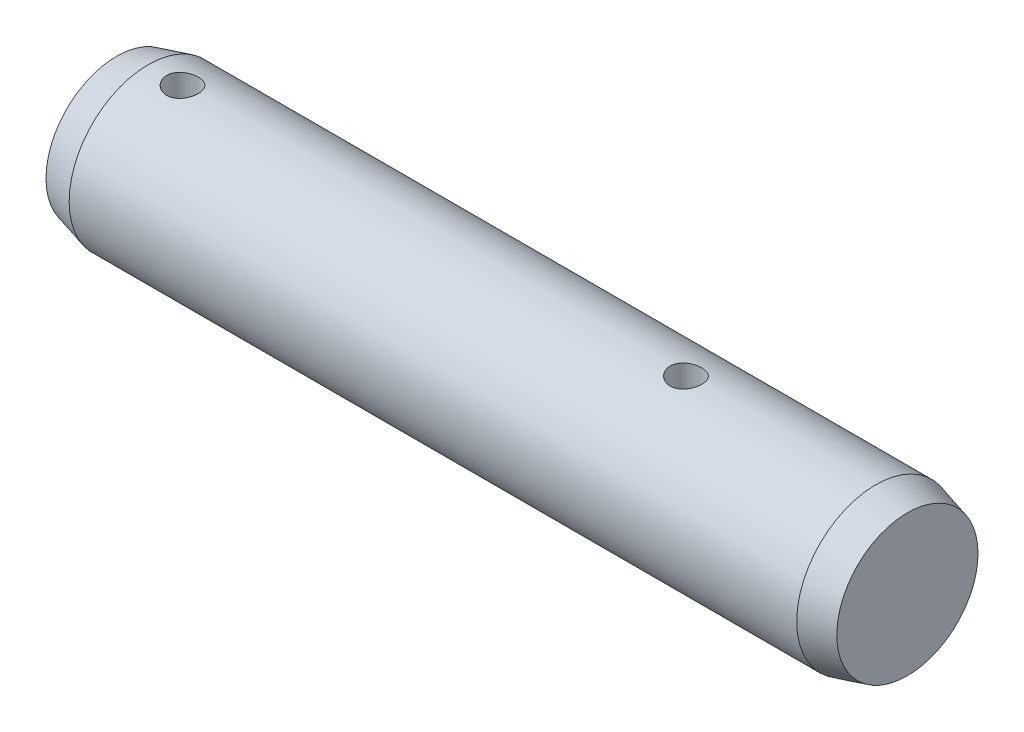
from build123d import *

# Parameters (mm, degrees)
SKETCH2_R           = 3
EXTRUDE1_DEPTH      = 13.8
EXTRUDE1_DEPTH_BACK = 13.8
SKETCH3_R           = 3
EXTRUDE2_DEPTH      = 1.2
EXTRUDE2_TAPER      = 15
SKETCH4_R           = 3
EXTRUDE3_DEPTH      = 1.2
EXTRUDE3_TAPER      = 15
SKETCH6_R           = 0.6
CUT_EXTRUDE1_DEPTH  = 5


with BuildPart() as part:
    # Sketch2 → Extrude1 (new body, two sides)
    with BuildSketch(Plane(origin=(0, 0, 0), x_dir=(0, 0, -1), z_dir=(1, 0, 0))) as extrude1_sk:
        Circle(SKETCH2_R)
    extrude(amount=EXTRUDE1_DEPTH)
    extrude(extrude1_sk.sketch, amount=-EXTRUDE1_DEPTH_BACK)

    # Sketch3 → Extrude2 (add)
    with BuildSketch(Plane(origin=(13.8, 0, 0), x_dir=(0, 0, -1), z_dir=(1, 0, 0))):
        Circle(SKETCH3_R)
    extrude(amount=EXTRUDE2_DEPTH, taper=EXTRUDE2_TAPER)

    # Sketch4 → Extrude3 (add)
    with BuildSketch(Plane.ZY.offset(13.8)):
        Circle(SKETCH4_R)
    extrude(amount=EXTRUDE3_DEPTH, taper=EXTRUDE3_TAPER)

    # Sketch6 → Cut-Extrude1 (cut, symmetric)
    with BuildSketch(Plane(origin=(0, 0, 0), x_dir=(1, 0, 0), z_dir=(0, 1, 0))):
        with Locations((6.6, 0)):
            Circle(SKETCH6_R)
        with Locations((-12.5, 0)):
            Circle(SKETCH6_R)
    extrude(amount=CUT_EXTRUDE1_DEPTH, both=True, mode=Mode.SUBTRACT)


solid = part.part
